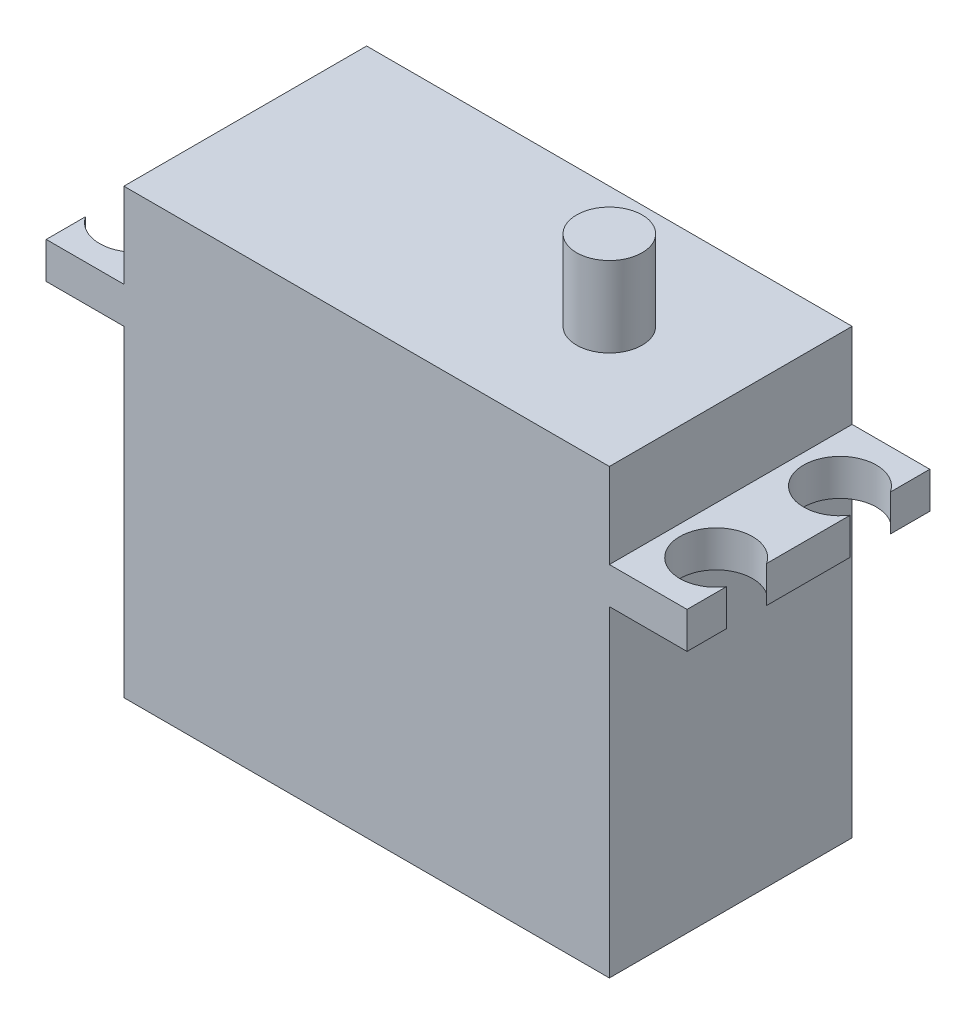
from build123d import *

# Parameters (mm, degrees)
EXTRUDE_1_DEPTH     = 20
SKETCH_2_R          = 3
CUT_EXTRUDE_1_DEPTH = 30.5
SKETCH_3_R          = 2.7
EXTRUDE_2_DEPTH     = 6.6


with BuildPart() as part:
    # 草圖1 → 填料-伸長1 (new body)
    with BuildSketch(Plane.XY):
        Polygon((0, -7), (-6.4, -7), (-6.4, -10), (0, -10), (0, -36.5), (40, -36.5), (40, -10), (46.4, -10), (46.4, -7), (40, -7), (40, 0), (0, 0), align=None)
    extrude(amount=EXTRUDE_1_DEPTH)

    # 草圖2 → 除料-伸長1 (cut, through all)
    with BuildSketch(Plane(origin=(0, -7, 0), x_dir=(1, 0, 0), z_dir=(0, 1, 0))):
        with Locations((-3.9, -4.9)):
            Circle(SKETCH_2_R)
        with Locations((-3.9, -15.1)):
            Circle(SKETCH_2_R)
        with Locations((43.9, -15.1)):
            Circle(SKETCH_2_R)
        with Locations((43.9, -4.9)):
            Circle(SKETCH_2_R)
    extrude(amount=-CUT_EXTRUDE_1_DEPTH, mode=Mode.SUBTRACT)

    # 草圖3 → 填料-伸長2 (add)
    with BuildSketch(Plane(origin=(0, 0, 0), x_dir=(1, 0, 0), z_dir=(0, 1, 0))):
        with Locations((30, -10)):
            Circle(SKETCH_3_R)
    extrude(amount=EXTRUDE_2_DEPTH)


solid = part.part
